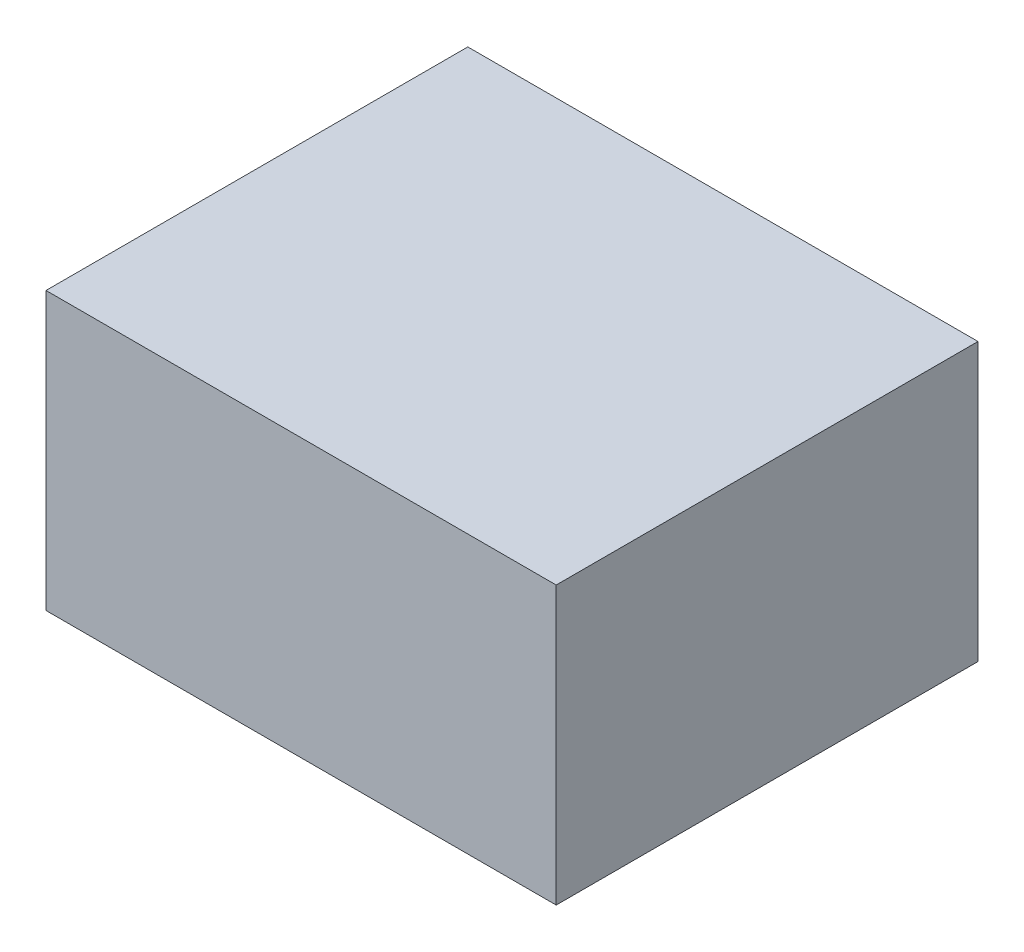
from build123d import *

# Parameters (mm, degrees)
SKETCH1_W           = 127
SKETCH1_H           = 105
SKETCH1_W_2         = 122
SKETCH1_H_2         = 100
BOSS_EXTRUDE3_DEPTH = 66.5
SKETCH4_W           = 127
SKETCH4_H           = 105
BOSS_EXTRUDE4_DEPTH = 2.5


with BuildPart() as part:
    # Sketch1 → Boss-Extrude3 (new body)
    with BuildSketch(Plane(origin=(0, 0, 0), x_dir=(1, 0, 0), z_dir=(0, 1, 0))):
        with Locations((-20.636546185, -9.658634538)):
            Rectangle(SKETCH1_W, SKETCH1_H)
        with Locations((-20.636546185, -9.658634538)):
            Rectangle(SKETCH1_W_2, SKETCH1_H_2, mode=Mode.SUBTRACT)
    extrude(amount=BOSS_EXTRUDE3_DEPTH)

    # Sketch4 → Boss-Extrude4 (add)
    with BuildSketch(Plane(origin=(0, 66.5, 0), x_dir=(1, 0, 0), z_dir=(0, 1, 0))):
        with Locations((-20.636546185, -9.658634538)):
            Rectangle(SKETCH4_W, SKETCH4_H)
    extrude(amount=BOSS_EXTRUDE4_DEPTH)


solid = part.part
